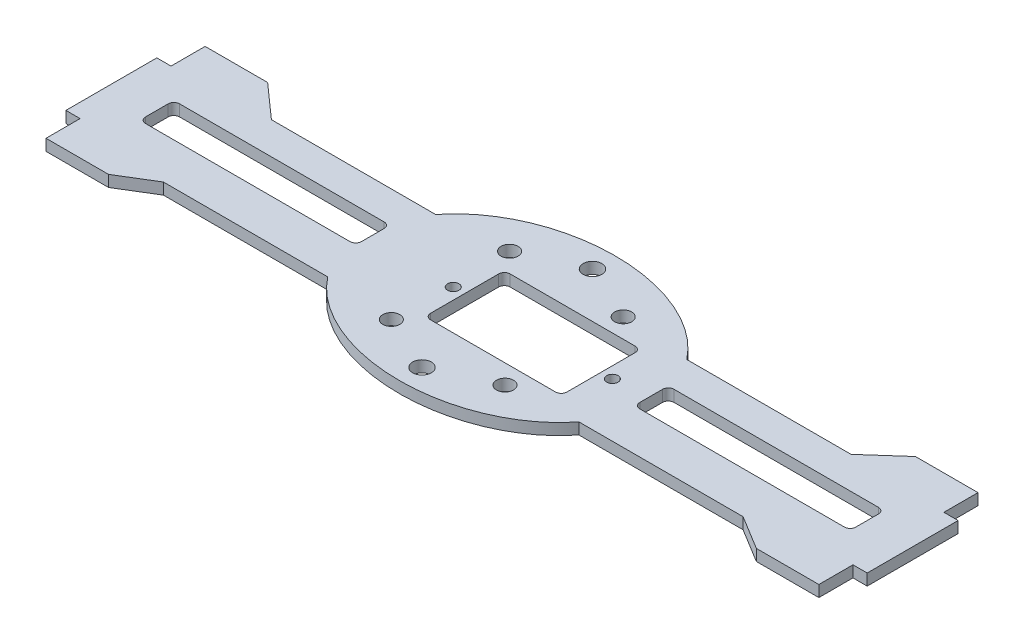
from build123d import *

# Parameters (mm, degrees)
RESSALTO_EXTRUS_O1_DEPTH = 2
ESBO_O2_R                = 1.65
ESBO_O2_R_2              = 1.5
ESBO_O2_R_3              = 1
CORTE_EXTRUS_O1_DEPTH    = 3.0000001


with BuildPart() as part:
    # Esboço1 → Ressalto-extrusão1 (new body)
    with BuildSketch(Plane(origin=(0, 0, 0), x_dir=(1, 0, 0), z_dir=(0, 1, 0))):
        with BuildLine():
            Line((-57, 14.836150135), (-51, 9.5))
            Line((-51, 9.5), (-22.083647797, 9.5))
            add(Edge.make_bspline(
                [(22.083647797, 9.5), (0, 38), (-22.083647797, 9.5)],
                knots=[0.523598776, 0.523598776, 0.523598776, 2.617993878, 2.617993878, 2.617993878], degree=2, weights=[1, 0.5, 1]))
            Line((22.083647797, 9.5), (51, 9.5))
            Line((51, 9.5), (57, 14.836150135))
            Line((57, 14.836150135), (68, 14.836150135))
            Line((68, 14.836150135), (68, 8.836150135))
            Line((68, 8.836150135), (70.5, 8.836150135))
            Line((70.5, 8.836150135), (70.5, -7.163849865))
            Line((70.5, -7.163849865), (68, -7.163849865))
            Line((68, -7.163849865), (68, -13.163849865))
            Line((68, -13.163849865), (57, -13.163849865))
            Line((57, -13.163849865), (51, -9.5))
            Line((51, -9.5), (22.083647797, -9.5))
            add(Edge.make_bspline(
                [(-22.083647797, -9.5), (0, -38), (22.083647797, -9.5)],
                knots=[3.665191429, 3.665191429, 3.665191429, 5.759586532, 5.759586532, 5.759586532], degree=2, weights=[1, 0.5, 1]))
            Line((-22.083647797, -9.5), (-51, -9.5))
            Line((-51, -9.5), (-57, -13.163849865))
            Line((-57, -13.163849865), (-68, -13.163849865))
            Line((-68, -13.163849865), (-68, -7.163849865))
            Line((-68, -7.163849865), (-70.5, -7.163849865))
            Line((-70.5, -7.163849865), (-70.5, 8.836150135))
            Line((-70.5, 8.836150135), (-68, 8.836150135))
            Line((-68, 8.836150135), (-68, 14.836150135))
            Line((-68, 14.836150135), (-57, 14.836150135))
        make_face()
    extrude(amount=RESSALTO_EXTRUS_O1_DEPTH)

    # Esboço2 → Corte-extrusão1 (cut, through all)
    with BuildSketch(Plane(origin=(0, 2, 0), x_dir=(1, 0, 0), z_dir=(0, 1, 0))):
        with Locations((0, 15)):
            Circle(ESBO_O2_R)
        with Locations((10, 10.4)):
            Circle(ESBO_O2_R_2)
        with Locations((-10, 10.4)):
            Circle(ESBO_O2_R_2)
        with Locations((0, -15)):
            Circle(ESBO_O2_R)
        with Locations((10, -10.4)):
            Circle(ESBO_O2_R_2)
        with Locations((-10, -10.4)):
            Circle(ESBO_O2_R_2)
        with Locations((-9.5, 0)):
            Circle(ESBO_O2_R_3)
        with Locations((18.5, 0)):
            Circle(ESBO_O2_R_3)
        with BuildLine():
            Line((25.5, 3.836150135), (61.5, 3.836150135))
            ThreePointArc((61.5, 3.836150135), (62.207106781, 3.543256916), (62.5, 2.836150135))
            Line((62.5, 2.836150135), (62.5, -1.163849865))
            ThreePointArc((62.5, -1.163849865), (62.207106781, -1.870956646), (61.5, -2.163849865))
            Line((61.5, -2.163849865), (25.5, -2.163849865))
            ThreePointArc((25.5, -2.163849865), (24.792893219, -1.870956646), (24.5, -1.163849865))
            Line((24.5, -1.163849865), (24.5, 2.836150135))
            ThreePointArc((24.5, 2.836150135), (24.792893219, 3.543256916), (25.5, 3.836150135))
        make_face()
        with BuildLine():
            Line((-61.5, 3.836150135), (-25.5, 3.836150135))
            ThreePointArc((-25.5, 3.836150135), (-24.792893219, 3.543256916), (-24.5, 2.836150135))
            Line((-24.5, 2.836150135), (-24.5, -1.163849865))
            ThreePointArc((-24.5, -1.163849865), (-24.792893219, -1.870956646), (-25.5, -2.163849865))
            Line((-25.5, -2.163849865), (-61.5, -2.163849865))
            ThreePointArc((-61.5, -2.163849865), (-62.207106781, -1.870956646), (-62.5, -1.163849865))
            Line((-62.5, -1.163849865), (-62.5, 2.836150135))
            ThreePointArc((-62.5, 2.836150135), (-62.207106781, 3.543256916), (-61.5, 3.836150135))
        make_face()
        with BuildLine():
            Line((-6.5, 7), (15.5, 7))
            ThreePointArc((15.5, 7), (16.207106781, 6.707106781), (16.5, 6))
            Line((16.5, 6), (16.5, -6))
            ThreePointArc((16.5, -6), (16.207106781, -6.707106781), (15.5, -7))
            Line((15.5, -7), (-6.5, -7))
            ThreePointArc((-6.5, -7), (-7.207106781, -6.707106781), (-7.5, -6))
            Line((-7.5, -6), (-7.5, 6))
            ThreePointArc((-7.5, 6), (-7.207106781, 6.707106781), (-6.5, 7))
        make_face()
    extrude(amount=-CORTE_EXTRUS_O1_DEPTH, mode=Mode.SUBTRACT)


solid = part.part
